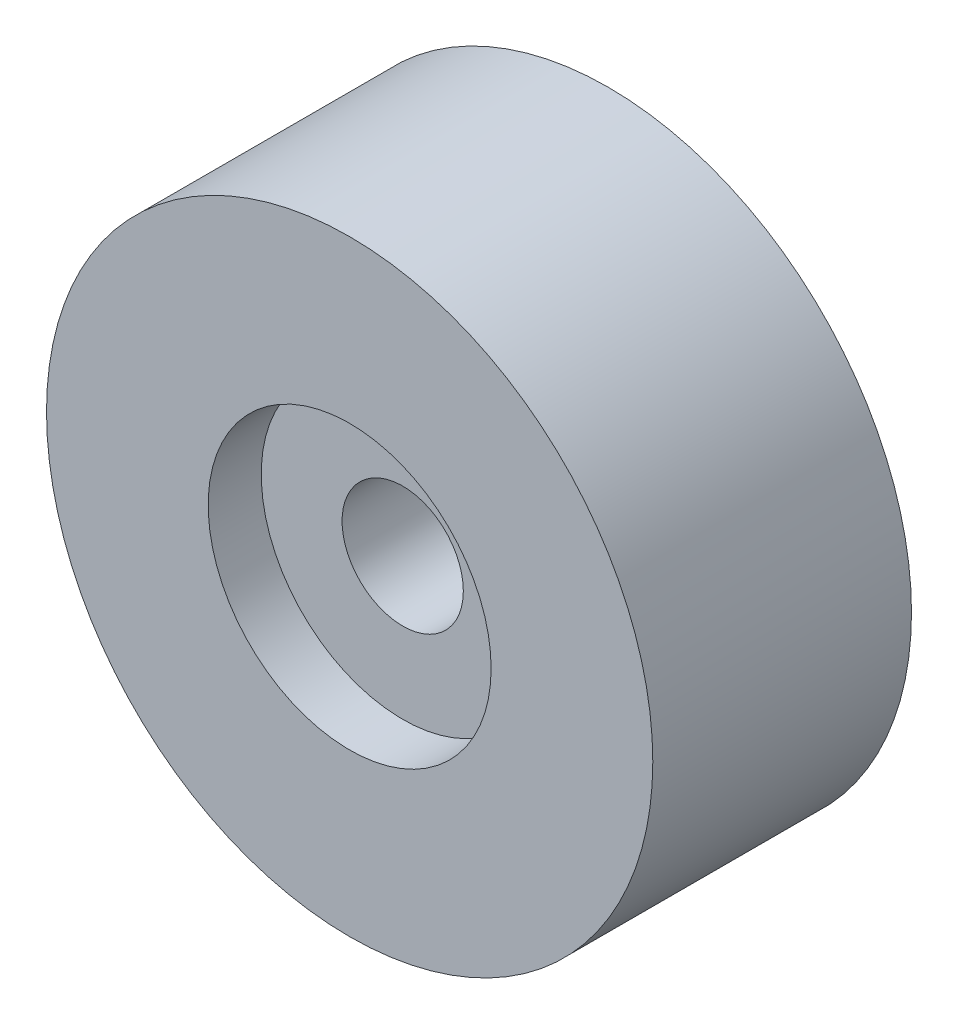
from build123d import *

# Parameters (mm, degrees)
SKETCH_1_R          = 30
SKETCH_1_R_2        = 6
EXTRUDE_1_DEPTH     = 25.6
SKETCH_2_R          = 14
CUT_EXTRUDE_1_DEPTH = 5.25


with BuildPart() as part:
    # ｽｹｯﾁ1 → ﾎﾞｽ - 押し出し1 (new body)
    with BuildSketch(Plane.XY):
        Circle(SKETCH_1_R)
        Circle(SKETCH_1_R_2, mode=Mode.SUBTRACT)
    extrude(amount=EXTRUDE_1_DEPTH)

    # ｽｹｯﾁ2 → ｶｯﾄ - 押し出し1 (cut)
    with BuildSketch(Plane.XY.offset(25.6)):
        Circle(SKETCH_2_R)
    extrude(amount=-CUT_EXTRUDE_1_DEPTH, mode=Mode.SUBTRACT)


solid = part.part
